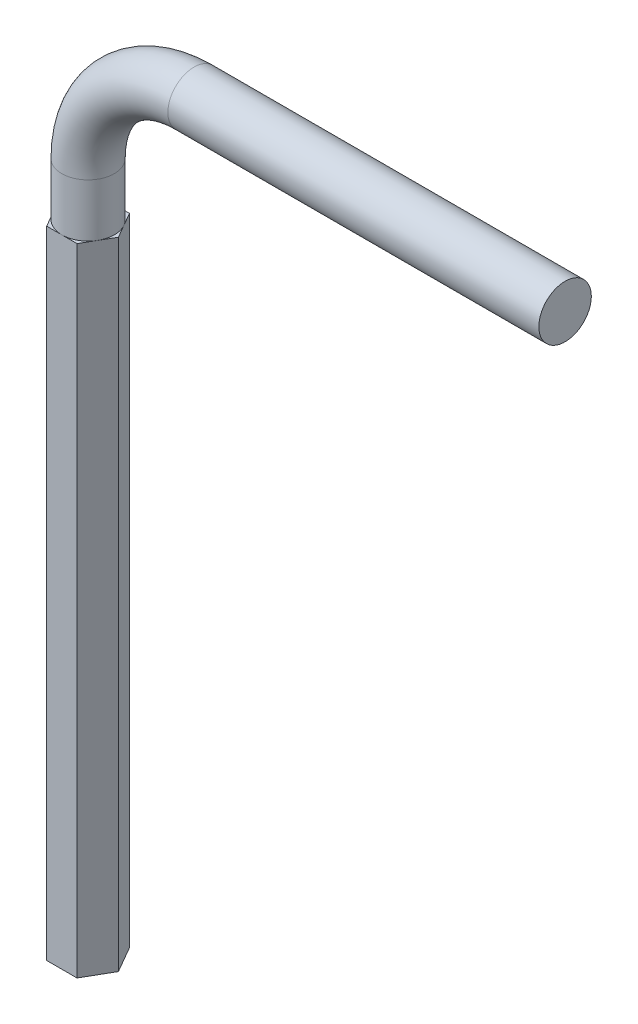
from build123d import *

# Parameters (mm, degrees)
SKETCH16_R          = 2.475
BOSS_EXTRUDE2_DEPTH = 60


with BuildPart() as part:
    # Sweep4: sweep along a path in Sketch15
    with BuildLine(Plane.XY) as sweep4_path:
        Line((0, 0), (0, 65))
        ThreePointArc((0, 65), (2.928932188, 72.071067812), (10, 75))
        Line((10, 75), (45, 75))
    # Sketch16 → Sweep4 (sweep)
    with BuildSketch(Plane(origin=(0, 0, 0), x_dir=(1, 0, 0), z_dir=(0, 1, 0))):
        Circle(SKETCH16_R)
    sweep(path=sweep4_path.line)

    # Sketch18 → Boss-Extrude2 (add)
    with BuildSketch(Plane(origin=(0, 0, 0), x_dir=(1, 0, 0), z_dir=(0, 1, 0))):
        Polygon((2.857883832, 0), (1.428941916, 2.475), (-1.428941916, 2.475), (-2.857883832, 0), (-1.428941916, -2.475), (1.428941916, -2.475), align=None)
    extrude(amount=BOSS_EXTRUDE2_DEPTH)


solid = part.part
